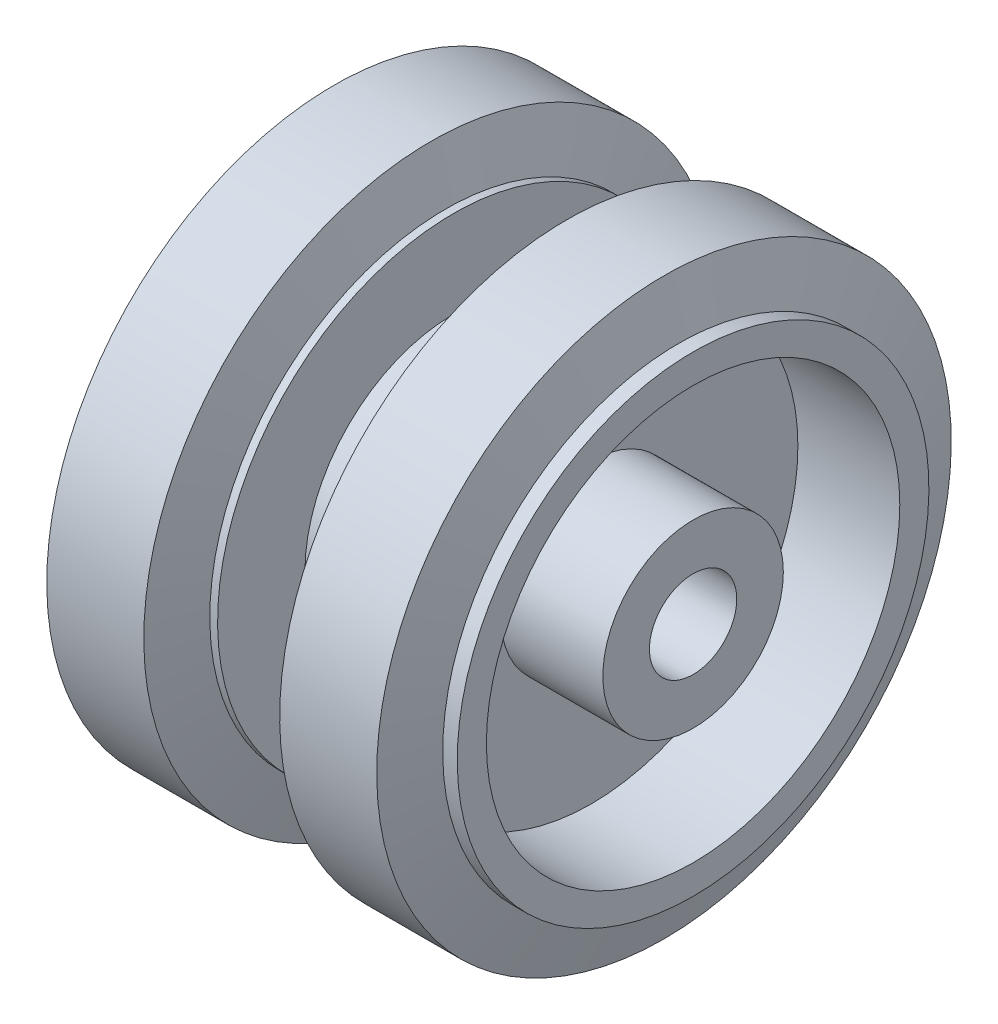
from build123d import *

# Parameters (mm, degrees)
SKETCH2_W   = 10.5
SKETCH2_H   = 12
SKETCH2_W_2 = 15
SKETCH2_H_2 = 4.5


with BuildPart() as part:
    # Sketch1 → Revolve1 (revolve)
    with BuildSketch(Plane.XY):
        Polygon((0, 0), (0, 15.3), (-4.7, 15.3), (-4.7, 24.3), (-5.5, 24.3), (-7, 29.6), (-17, 29.6), (-18.5, 24.3), (-20, 24.3), (-20, 0), align=None)
    revolve1 = revolve(axis=Axis((-20, 0, 0), (1, 0, 0)))

    # Sketch2 → Cut-Revolve1 (revolve, cut)
    with BuildSketch(Plane.XY):
        with Locations((-14.75, 15.3)):
            Rectangle(SKETCH2_W, SKETCH2_H)
        with Locations((-12.5, 2.25)):
            Rectangle(SKETCH2_W_2, SKETCH2_H_2)
    cut_revolve1 = revolve(axis=Axis((0, 0, 0), (-1, 0, 0)), mode=Mode.SUBTRACT)

    # Mirror1: Revolve1, Cut-Revolve1 across plane
    add(revolve1.mirror(Plane.ZY))
    add(cut_revolve1.mirror(Plane.ZY), mode=Mode.SUBTRACT)


solid = part.part
